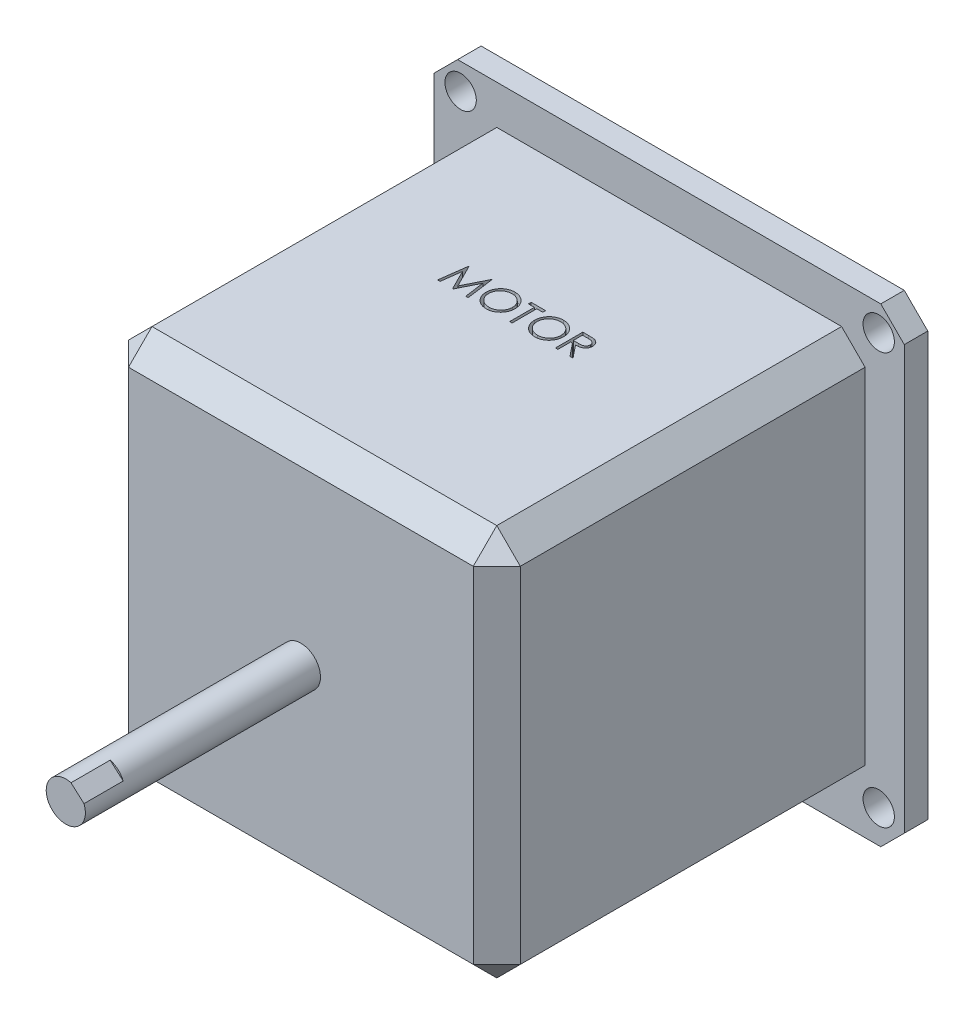
from build123d import *

# Parameters (mm, degrees)
SKETCH1_W             = 50
SKETCH1_H             = 50
BOSS_EXTRUDE1_DEPTH   = 25
CHAMFER1_SIZE         = 3
SKETCH2_R             = 2.5
BOSS_EXTRUDE2_DEPTH   = 50
CUT_EXTRUDE1_DEPTH    = 3
BOSS_EXTRUDE3_DEPTH   = 5
SKETCH5_W             = 60
SKETCH5_H             = 60
BOSS_EXTRUDE4_DEPTH   = 3
F_4_0MM_DOWEL_HOLE1_D = 4
CHAMFER2_SIZE         = 3


with BuildPart() as part:
    # Sketch1 → Boss-Extrude1 (new body, symmetric)
    with BuildSketch(Plane.XY):
        Rectangle(SKETCH1_W, SKETCH1_H)
    extrude(amount=BOSS_EXTRUDE1_DEPTH, both=True)

    # Chamfer1
    chamfer1_edges = [part.edges().sort_by_distance(p)[0] for p in [
        (-25, 0, 25),
        (0, -25, 25),
        (25, 0, 25),
        (0, -25, -25),
        (-25, 0, -25),
        (0, 25, -25),
        (25, 0, -25),
        (0, 25, 25),
        (25, -25, 0),
        (-25, -25, 0),
        (-25, 25, 0),
        (25, 25, 0),
    ]]
    chamfer(chamfer1_edges, length=CHAMFER1_SIZE)

    # Sketch2 → Boss-Extrude2 (add)
    with BuildSketch(Plane.XY):
        Circle(SKETCH2_R)
    extrude(amount=BOSS_EXTRUDE2_DEPTH)

    # Sketch3 → Cut-Extrude1 (cut)
    with BuildSketch(Plane(origin=(0, 25, 0), x_dir=(1, 0, 0), z_dir=(0, 1, 0))):
        Polygon((-8.921076978, 1.368655092), (-8.459037716, 4.868655092), (-8.414165921, 4.868655092), (-6.969153901, 1.99686022), (-5.527647491, 4.868655092), (-5.482074575, 4.868655092), (-5.017230825, 1.368655092), (-5.332735632, 1.368655092), (-5.66787185, 3.887084579), (-6.931293325, 1.368655092), (-7.002106626, 1.368655092), (-8.270435953, 3.892693553), (-8.604871049, 1.368655092), align=None)
        with BuildLine():
            add(Edge.make_bspline(
                [(-2.661461594, 4.958398681), (-2.596653488, 4.956757202), (-2.469365021, 4.953533201), (-2.282290123, 4.928854097), (-2.103695028, 4.886158708), (-1.932124889, 4.829295725), (-1.769631913, 4.75344134), (-1.61499302, 4.661756191), (-1.468576146, 4.553279733), (-1.332354765, 4.428850506), (-1.207697814, 4.293467052), (-1.097871928, 4.148989142), (-1.005829634, 3.996290339), (-0.930243847, 3.835829509), (-0.870945238, 3.667969541), (-0.830026194, 3.491815538), (-0.803888044, 3.308508848), (-0.800832266, 3.183481983), (-0.799282107, 3.120057335)],
                knots=[0, 0, 0, 0, 0.000194393, 0.000381804, 0.00056479, 0.000744601, 0.000923091, 0.001101652, 0.001283106, 0.001468738, 0.001654324, 0.001834514, 0.002012231, 0.002188181, 0.002365797, 0.002545211, 0.002729936, 0.002920126, 0.002920126, 0.002920126, 0.002920126], degree=3))
            add(Edge.make_bspline(
                [(-0.799282107, 3.120057335), (-0.800832039, 3.057099889), (-0.803887136, 2.933003468), (-0.830055913, 2.750860024), (-0.871096913, 2.575769328), (-0.929693179, 2.408023675), (-1.004918658, 2.247446111), (-1.097573829, 2.094459157), (-1.20671504, 1.949012659), (-1.330921891, 1.812699994), (-1.466322933, 1.687702523), (-1.6115532, 1.578783647), (-1.76334652, 1.485059523), (-1.923656228, 1.410275849), (-2.090356265, 1.350503928), (-2.264938588, 1.309751298), (-2.446585142, 1.283464255), (-2.570456145, 1.280445739), (-2.633416722, 1.278911502)],
                knots=[0, 0, 0, 0, 0.000188789, 0.000372126, 0.000550857, 0.00072758, 0.000904164, 0.001081881, 0.001263191, 0.001448823, 0.00163441, 0.001815159, 0.001992641, 0.002168591, 0.002344885, 0.002522934, 0.002705576, 0.002894365, 0.002894365, 0.002894365, 0.002894365], degree=3))
            add(Edge.make_bspline(
                [(-2.633416722, 1.278911502), (-2.696841041, 1.280460889), (-2.821867257, 1.283515143), (-3.005404292, 1.309696547), (-3.181682036, 1.350637851), (-3.350196387, 1.409147287), (-3.511041317, 1.484764518), (-3.6645314, 1.576968897), (-3.810050547, 1.686376038), (-3.946392293, 1.810542613), (-4.071141492, 1.945714165), (-4.179900867, 2.09054842), (-4.272125981, 2.242203877), (-4.347489313, 2.401101401), (-4.407153772, 2.566472844), (-4.447858591, 2.739421321), (-4.474194543, 2.918960827), (-4.477229389, 3.041203725), (-4.478769286, 3.103230412)],
                knots=[0, 0, 0, 0, 0.00019019, 0.000374915, 0.000555011, 0.000732396, 0.00090898, 0.001087298, 0.001268608, 0.00145424, 0.001639827, 0.001819595, 0.001996712, 0.002171394, 0.002346367, 0.002523053, 0.002703612, 0.002889599, 0.002889599, 0.002889599, 0.002889599], degree=3))
            add(Edge.make_bspline(
                [(-4.478769286, 3.103230412), (-4.478234651, 3.144863081), (-4.477172124, 3.227603205), (-4.464380432, 3.350469805), (-4.445818731, 3.471360463), (-4.419216818, 3.589931411), (-4.384425151, 3.705892395), (-4.343373124, 3.820043158), (-4.293233278, 3.931226882), (-4.23655263, 4.039970274), (-4.173290822, 4.144578179), (-4.103415073, 4.243457763), (-4.029379704, 4.337438759), (-3.948216311, 4.424085763), (-3.862599866, 4.50591942), (-3.771141487, 4.581682137), (-3.674399243, 4.652057088), (-3.571956863, 4.715477429), (-3.466338588, 4.772836563), (-3.357461811, 4.822058414), (-3.246805239, 4.864304476), (-3.133850591, 4.898545301), (-3.018897819, 4.925577337), (-2.901696034, 4.943984691), (-2.782338608, 4.956809009), (-2.701927289, 4.957866511), (-2.661461594, 4.958398681)],
                knots=[0, 0, 0, 0, 0.000124849, 0.000248123, 0.000370193, 0.00049164, 0.000612319, 0.000733199, 0.000855287, 0.000977905, 0.001100913, 0.001221706, 0.001340948, 0.001459521, 0.001577551, 0.001696047, 0.001815534, 0.001936153, 0.002057243, 0.002175846, 0.002294342, 0.002412335, 0.002529682, 0.00264829, 0.002768075, 0.00288942, 0.00288942, 0.00288942, 0.00288942], degree=3))
        make_face()
        with BuildLine():
            add(Edge.make_bspline(
                [(-2.646036914, 4.599424322), (-2.679251548, 4.599019432), (-2.745363281, 4.598213522), (-2.843647817, 4.587597807), (-2.940639751, 4.572467918), (-3.036359113, 4.550886397), (-3.130405402, 4.521482344), (-3.223655244, 4.487641436), (-3.315258297, 4.446420345), (-3.404912155, 4.399847641), (-3.49182723, 4.34829872), (-3.573839932, 4.291326953), (-3.651162576, 4.230268399), (-3.723605843, 4.164980562), (-3.790957015, 4.09513096), (-3.854541716, 4.021778524), (-3.911811298, 3.942826633), (-3.964296875, 3.860416226), (-4.011264715, 3.774654645), (-4.05303007, 3.686444782), (-4.087194078, 3.595067096), (-4.115056455, 3.501512938), (-4.138156266, 3.405930478), (-4.15279019, 3.30759463), (-4.163522549, 3.206999517), (-4.164282395, 3.139017663), (-4.164666722, 3.104632656)],
                knots=[0, 0, 0, 0, 9.9599e-05, 0.000198245, 0.000296222, 0.00039402, 0.00049227, 0.000591646, 0.000691452, 0.000793368, 0.000894612, 0.000994383, 0.001092713, 0.00119001, 0.001286696, 0.001383657, 0.001480979, 0.001579008, 0.001676595, 0.001774142, 0.001871547, 0.001968922, 0.002066879, 0.00216624, 0.00226698, 0.002370083, 0.002370083, 0.002370083, 0.002370083], degree=3))
            add(Edge.make_bspline(
                [(-4.164666722, 3.104632656), (-4.16339186, 3.054070435), (-4.160883812, 2.954598905), (-4.138926242, 2.808830761), (-4.105104268, 2.668742474), (-4.055246901, 2.535100565), (-3.992896287, 2.406756282), (-3.915869396, 2.284848178), (-3.824610311, 2.169343303), (-3.720946784, 2.061048034), (-3.607624077, 1.96220223), (-3.487291348, 1.875438821), (-3.36123774, 1.802028572), (-3.229134537, 1.742223499), (-3.091686998, 1.694833761), (-2.948009447, 1.66235513), (-2.799058988, 1.640979675), (-2.697528333, 1.638926919), (-2.646036914, 1.637885861)],
                knots=[0, 0, 0, 0, 0.000151605, 0.000298253, 0.000441263, 0.000583229, 0.000725274, 0.000868635, 0.001014928, 0.001166177, 0.001317744, 0.00146543, 0.001610576, 0.001754594, 0.001899821, 0.002045914, 0.002195936, 0.002350312, 0.002350312, 0.002350312, 0.002350312], degree=3))
            add(Edge.make_bspline(
                [(-2.646036914, 1.637885861), (-2.611427413, 1.638361365), (-2.542786376, 1.639304433), (-2.440690854, 1.64880311), (-2.340434642, 1.664034979), (-2.242158362, 1.685965635), (-2.145973551, 1.713412841), (-2.051478748, 1.746020569), (-1.959680458, 1.786701773), (-1.86942062, 1.831649725), (-1.783024378, 1.882889882), (-1.700548846, 1.937928032), (-1.624072866, 1.998896653), (-1.551683794, 2.063214465), (-1.484056105, 2.132178313), (-1.421647121, 2.205698535), (-1.364666989, 2.284239192), (-1.312201343, 2.366524598), (-1.26539808, 2.45252085), (-1.224618981, 2.541050528), (-1.190022865, 2.631895638), (-1.16209436, 2.725187209), (-1.140208898, 2.820748058), (-1.125128978, 2.918706136), (-1.11458054, 3.018865479), (-1.113785463, 3.086609335), (-1.113384671, 3.120758457)],
                knots=[0, 0, 0, 0, 0.000103804, 0.000205874, 0.000307314, 0.000407849, 0.000507719, 0.000607281, 0.000707445, 0.000808723, 0.000909609, 0.001008589, 0.001105934, 0.001202762, 0.001298946, 0.001395452, 0.001491794, 0.001589823, 0.001688026, 0.001785277, 0.001882027, 0.001979402, 0.0020772, 0.002175869, 0.002276609, 0.002379011, 0.002379011, 0.002379011, 0.002379011], degree=3))
            add(Edge.make_bspline(
                [(-1.113384671, 3.120758457), (-1.113785784, 3.154673961), (-1.114581465, 3.221951611), (-1.12512394, 3.32141243), (-1.14022483, 3.418665641), (-1.161987538, 3.513329444), (-1.190037692, 3.605427969), (-1.224625022, 3.694874717), (-1.265410322, 3.782002912), (-1.312218546, 3.866597209), (-1.36483437, 3.947771947), (-1.422328613, 4.02537436), (-1.485693961, 4.097947101), (-1.553119986, 4.167281795), (-1.626290871, 4.231899685), (-1.704875165, 4.291822205), (-1.787918843, 4.34849548), (-1.875846079, 4.399621041), (-1.966590032, 4.446835274), (-2.05970399, 4.487286277), (-2.15413309, 4.521658397), (-2.249637202, 4.550975362), (-2.347020181, 4.572383392), (-2.445624009, 4.587611442), (-2.545312268, 4.598209828), (-2.612355488, 4.599018206), (-2.646036914, 4.599424322)],
                knots=[0, 0, 0, 0, 0.000101701, 0.000201743, 0.00029972, 0.000396835, 0.000492868, 0.000588308, 0.000684288, 0.000781261, 0.000878109, 0.000974304, 0.001070733, 0.001166917, 0.001264269, 0.001363274, 0.001463228, 0.001565678, 0.001668217, 0.001769947, 0.001869982, 0.001969573, 0.002069423, 0.002168785, 0.002268827, 0.002369827, 0.002369827, 0.002369827, 0.002369827], degree=3))
        make_face(mode=Mode.SUBTRACT)
        Polygon((-0.485179543, 4.509680733), (-0.485179543, 4.868655092), (1.354564047, 4.868655092), (1.354564047, 4.509680733), (0.591743534, 4.509680733), (0.591743534, 1.368655092), (0.27764097, 1.368655092), (0.27764097, 4.509680733), align=None)
        with BuildLine():
            add(Edge.make_bspline(
                [(3.530846099, 4.958398681), (3.595654204, 4.956757202), (3.722942671, 4.953533201), (3.910017569, 4.928854097), (4.088612664, 4.886158708), (4.260182803, 4.829295725), (4.42267578, 4.75344134), (4.577314672, 4.661756191), (4.723731546, 4.553279733), (4.859952928, 4.428850506), (4.984609878, 4.293467052), (5.094435764, 4.148989142), (5.186478058, 3.996290339), (5.262063845, 3.835829509), (5.321362455, 3.667969541), (5.362281498, 3.491815538), (5.388419649, 3.308508848), (5.391475426, 3.183481983), (5.393025586, 3.120057335)],
                knots=[0, 0, 0, 0, 0.000194393, 0.000381804, 0.00056479, 0.000744601, 0.000923091, 0.001101652, 0.001283106, 0.001468738, 0.001654324, 0.001834514, 0.002012231, 0.002188181, 0.002365797, 0.002545211, 0.002729936, 0.002920126, 0.002920126, 0.002920126, 0.002920126], degree=3))
            add(Edge.make_bspline(
                [(5.393025586, 3.120057335), (5.391475653, 3.057099889), (5.388420557, 2.933003468), (5.362251779, 2.750860024), (5.321210779, 2.575769328), (5.262614513, 2.408023675), (5.187389034, 2.247446111), (5.094733863, 2.094459157), (4.985592653, 1.949012659), (4.861385802, 1.812699994), (4.72598476, 1.687702523), (4.580754493, 1.578783647), (4.428961173, 1.485059523), (4.268651465, 1.410275849), (4.101951428, 1.350503928), (3.927369105, 1.309751298), (3.745722551, 1.283464255), (3.621851547, 1.280445739), (3.55889097, 1.278911502)],
                knots=[0, 0, 0, 0, 0.000188789, 0.000372126, 0.000550857, 0.00072758, 0.000904164, 0.001081881, 0.001263191, 0.001448823, 0.00163441, 0.001815159, 0.001992641, 0.002168591, 0.002344885, 0.002522934, 0.002705576, 0.002894365, 0.002894365, 0.002894365, 0.002894365], degree=3))
            add(Edge.make_bspline(
                [(3.55889097, 1.278911502), (3.495466651, 1.280460889), (3.370440435, 1.283515143), (3.1869034, 1.309696547), (3.010625656, 1.350637851), (2.842111305, 1.409147287), (2.681266375, 1.484764518), (2.527776293, 1.576968897), (2.382257145, 1.686376038), (2.245915399, 1.810542613), (2.121166201, 1.945714165), (2.012406825, 2.09054842), (1.920181712, 2.242203877), (1.844818379, 2.401101401), (1.78515392, 2.566472844), (1.744449102, 2.739421321), (1.71811315, 2.918960827), (1.715078303, 3.041203725), (1.713538406, 3.103230412)],
                knots=[0, 0, 0, 0, 0.00019019, 0.000374915, 0.000555011, 0.000732396, 0.00090898, 0.001087298, 0.001268608, 0.00145424, 0.001639827, 0.001819595, 0.001996712, 0.002171394, 0.002346367, 0.002523053, 0.002703612, 0.002889599, 0.002889599, 0.002889599, 0.002889599], degree=3))
            add(Edge.make_bspline(
                [(1.713538406, 3.103230412), (1.714073042, 3.144863081), (1.715135568, 3.227603205), (1.727927261, 3.350469805), (1.746488962, 3.471360463), (1.773090874, 3.589931411), (1.807882541, 3.705892395), (1.848934569, 3.820043158), (1.899074414, 3.931226882), (1.955755062, 4.039970274), (2.01901687, 4.144578179), (2.08889262, 4.243457763), (2.162927988, 4.337438759), (2.244091382, 4.424085763), (2.329707827, 4.50591942), (2.421166205, 4.581682137), (2.517908449, 4.652057088), (2.620350829, 4.715477429), (2.725969104, 4.772836563), (2.834845882, 4.822058414), (2.945502453, 4.864304476), (3.058457101, 4.898545301), (3.173409873, 4.925577337), (3.290611658, 4.943984691), (3.409969084, 4.956809009), (3.490380403, 4.957866511), (3.530846099, 4.958398681)],
                knots=[0, 0, 0, 0, 0.000124849, 0.000248123, 0.000370193, 0.00049164, 0.000612319, 0.000733199, 0.000855287, 0.000977905, 0.001100913, 0.001221706, 0.001340948, 0.001459521, 0.001577551, 0.001696047, 0.001815534, 0.001936153, 0.002057243, 0.002175846, 0.002294342, 0.002412335, 0.002529682, 0.00264829, 0.002768075, 0.00288942, 0.00288942, 0.00288942, 0.00288942], degree=3))
        make_face()
        with BuildLine():
            add(Edge.make_bspline(
                [(3.546270778, 4.599424322), (3.513056144, 4.599019432), (3.446944412, 4.598213522), (3.348659875, 4.587597807), (3.251667941, 4.572467918), (3.155948579, 4.550886397), (3.06190229, 4.521482344), (2.968652449, 4.487641436), (2.877049395, 4.446420345), (2.787395537, 4.399847641), (2.700480462, 4.34829872), (2.61846776, 4.291326953), (2.541145116, 4.230268399), (2.46870185, 4.164980562), (2.401350678, 4.09513096), (2.337765976, 4.021778524), (2.280496394, 3.942826633), (2.228010818, 3.860416226), (2.181042977, 3.774654645), (2.139277623, 3.686444782), (2.105113614, 3.595067096), (2.077251238, 3.501512938), (2.054151427, 3.405930478), (2.039517503, 3.30759463), (2.028785143, 3.206999517), (2.028025298, 3.139017663), (2.02764097, 3.104632656)],
                knots=[0, 0, 0, 0, 9.9599e-05, 0.000198245, 0.000296222, 0.00039402, 0.00049227, 0.000591646, 0.000691452, 0.000793368, 0.000894612, 0.000994383, 0.001092713, 0.00119001, 0.001286696, 0.001383657, 0.001480979, 0.001579008, 0.001676595, 0.001774142, 0.001871547, 0.001968922, 0.002066879, 0.00216624, 0.00226698, 0.002370083, 0.002370083, 0.002370083, 0.002370083], degree=3))
            add(Edge.make_bspline(
                [(2.02764097, 3.104632656), (2.028915832, 3.054070435), (2.03142388, 2.954598905), (2.05338145, 2.808830761), (2.087203425, 2.668742474), (2.137060791, 2.535100565), (2.199411406, 2.406756282), (2.276438296, 2.284848178), (2.367697382, 2.169343303), (2.471360908, 2.061048034), (2.584683615, 1.96220223), (2.705016345, 1.875438821), (2.831069952, 1.802028572), (2.963173155, 1.742223499), (3.100620694, 1.694833761), (3.244298245, 1.66235513), (3.393248705, 1.640979675), (3.49477936, 1.638926919), (3.546270778, 1.637885861)],
                knots=[0, 0, 0, 0, 0.000151605, 0.000298253, 0.000441263, 0.000583229, 0.000725274, 0.000868635, 0.001014928, 0.001166177, 0.001317744, 0.00146543, 0.001610576, 0.001754594, 0.001899821, 0.002045914, 0.002195936, 0.002350312, 0.002350312, 0.002350312, 0.002350312], degree=3))
            add(Edge.make_bspline(
                [(3.546270778, 1.637885861), (3.58088028, 1.638361365), (3.649521316, 1.639304433), (3.751616838, 1.64880311), (3.85187305, 1.664034979), (3.95014933, 1.685965635), (4.046334141, 1.713412841), (4.140828944, 1.746020569), (4.232627235, 1.786701773), (4.322887073, 1.831649725), (4.409283314, 1.882889882), (4.491758847, 1.937928032), (4.568234826, 1.998896653), (4.640623898, 2.063214465), (4.708251587, 2.132178313), (4.770660571, 2.205698535), (4.827640703, 2.284239192), (4.88010635, 2.366524598), (4.926909613, 2.45252085), (4.967688712, 2.541050528), (5.002284827, 2.631895638), (5.030213332, 2.725187209), (5.052098794, 2.820748058), (5.067178714, 2.918706136), (5.077727152, 3.018865479), (5.07852223, 3.086609335), (5.078923022, 3.120758457)],
                knots=[0, 0, 0, 0, 0.000103804, 0.000205874, 0.000307314, 0.000407849, 0.000507719, 0.000607281, 0.000707445, 0.000808723, 0.000909609, 0.001008589, 0.001105934, 0.001202762, 0.001298946, 0.001395452, 0.001491794, 0.001589823, 0.001688026, 0.001785277, 0.001882027, 0.001979402, 0.0020772, 0.002175869, 0.002276609, 0.002379011, 0.002379011, 0.002379011, 0.002379011], degree=3))
            add(Edge.make_bspline(
                [(5.078923022, 3.120758457), (5.078521909, 3.154673961), (5.077726227, 3.221951611), (5.067183752, 3.32141243), (5.052082862, 3.418665641), (5.030320154, 3.513329444), (5.00227, 3.605427969), (4.96768267, 3.694874717), (4.92689737, 3.782002912), (4.880089146, 3.866597209), (4.827473323, 3.947771947), (4.769979079, 4.02537436), (4.706613731, 4.097947101), (4.639187706, 4.167281795), (4.566016821, 4.231899685), (4.487432527, 4.291822205), (4.404388849, 4.34849548), (4.316461614, 4.399621041), (4.22571766, 4.446835274), (4.132603702, 4.487286277), (4.038174602, 4.521658397), (3.94267049, 4.550975362), (3.845287512, 4.572383392), (3.746683683, 4.587611442), (3.646995424, 4.598209828), (3.579952205, 4.599018206), (3.546270778, 4.599424322)],
                knots=[0, 0, 0, 0, 0.000101701, 0.000201743, 0.00029972, 0.000396835, 0.000492868, 0.000588308, 0.000684288, 0.000781261, 0.000878109, 0.000974304, 0.001070733, 0.001166917, 0.001264269, 0.001363274, 0.001463228, 0.001565678, 0.001668217, 0.001769947, 0.001869982, 0.001969573, 0.002069423, 0.002168785, 0.002268827, 0.002369827, 0.002369827, 0.002369827, 0.002369827], degree=3))
        make_face(mode=Mode.SUBTRACT)
        with BuildLine():
            Line((6.110974304, 4.868655092), (6.811394977, 4.868655092))
            add(Edge.make_bspline(
                [(6.811394977, 4.868655092), (6.858136105, 4.868499506), (6.94788425, 4.868200763), (7.07645752, 4.866535), (7.193284617, 4.861760645), (7.298304456, 4.857652061), (7.391515111, 4.85016012), (7.473202402, 4.842999473), (7.5429901, 4.833625812), (7.585235951, 4.824920389), (7.604363727, 4.82097881)],
                knots=[0, 0, 0, 0, 0.000140226, 0.00026925, 0.000385712, 0.000490995, 0.000584507, 0.000666202, 0.000736998, 0.000795574, 0.000795574, 0.000795574, 0.000795574], degree=3))
            add(Edge.make_bspline(
                [(7.604363727, 4.82097881), (7.629970351, 4.814652044), (7.68063734, 4.802133481), (7.753587406, 4.77567388), (7.82310173, 4.745054255), (7.888891555, 4.709090535), (7.950627346, 4.667515755), (8.008945657, 4.621047633), (8.06411112, 4.569940427), (8.11389275, 4.512905585), (8.160831802, 4.453069076), (8.200420428, 4.388365319), (8.234546908, 4.320703791), (8.261717425, 4.249396374), (8.283595399, 4.175134602), (8.299021638, 4.097245805), (8.308272826, 4.01608483), (8.309214681, 3.960726921), (8.309692252, 3.932657495)],
                knots=[0, 0, 0, 0, 7.9081e-05, 0.000156475, 0.000232432, 0.000306798, 0.00038108, 0.000455429, 0.000530331, 0.000606314, 0.000682321, 0.000758201, 0.000833453, 0.000909362, 0.000986794, 0.001065445, 0.001147284, 0.001231465, 0.001231465, 0.001231465, 0.001231465], degree=3))
            add(Edge.make_bspline(
                [(8.309692252, 3.932657495), (8.308223254, 3.886022391), (8.305356858, 3.795025223), (8.278631755, 3.662964342), (8.234855235, 3.539775027), (8.174531946, 3.425612389), (8.09771247, 3.322701744), (8.005387679, 3.232311288), (7.897506068, 3.156671376), (7.797076752, 3.104218571), (7.708362552, 3.070625662), (7.635329239, 3.046989304), (7.555662262, 3.028727338), (7.470124927, 3.012367206), (7.378361272, 3.000015512), (7.280591232, 2.990968918), (7.176745081, 2.985314869), (7.105406011, 2.984472864), (7.068706675, 2.984039707)],
                knots=[0, 0, 0, 0, 0.000139777, 0.000272741, 0.000402249, 0.000530843, 0.000658588, 0.000786009, 0.000916741, 0.001052522, 0.001124656, 0.001201155, 0.001282612, 0.001369656, 0.001462366, 0.001560247, 0.001664165, 0.001774261, 0.001774261, 0.001774261, 0.001774261], degree=3))
            Line((7.068706675, 2.984039707), (8.354564047, 1.368655092))
            Line((8.354564047, 1.368655092), (7.966142573, 1.368655092))
            Line((7.966142573, 1.368655092), (6.680285201, 2.984039707))
            Line((6.680285201, 2.984039707), (6.425076868, 2.984039707))
            Line((6.425076868, 2.984039707), (6.425076868, 1.368655092))
            Line((6.425076868, 1.368655092), (6.110974304, 1.368655092))
            Line((6.110974304, 1.368655092), (6.110974304, 4.868655092))
        make_face()
        with BuildLine():
            Line((6.425076868, 4.509680733), (6.425076868, 3.343014066))
            Line((6.425076868, 3.343014066), (7.065902188, 3.338106213))
            add(Edge.make_bspline(
                [(7.065902188, 3.338106213), (7.095822227, 3.338092977), (7.153815784, 3.33806732), (7.237716449, 3.342061097), (7.315836561, 3.346604415), (7.387877313, 3.35355376), (7.453870888, 3.362509832), (7.513784301, 3.373712816), (7.567715353, 3.386764879), (7.630613892, 3.406966505), (7.700850423, 3.438972523), (7.777181883, 3.485538022), (7.842184221, 3.544107141), (7.897102083, 3.611080597), (7.941231515, 3.684716846), (7.972343569, 3.764133215), (7.992086011, 3.847324813), (7.994414557, 3.904502921), (7.995589688, 3.933358617)],
                knots=[0, 0, 0, 0, 8.9746e-05, 0.000173954, 0.000251933, 0.000324488, 0.000391021, 0.000451663, 0.000507268, 0.000557378, 0.000649639, 0.000738152, 0.000824558, 0.000910739, 0.000997194, 0.001080909, 0.00116578, 0.001252248, 0.001252248, 0.001252248, 0.001252248], degree=3))
            add(Edge.make_bspline(
                [(7.995589688, 3.933358617), (7.994387567, 3.961505191), (7.992005402, 4.01728143), (7.972556633, 4.09893734), (7.939667252, 4.17600429), (7.895345014, 4.248168775), (7.841345859, 4.313674511), (7.778028046, 4.369721664), (7.707122851, 4.415971129), (7.640851653, 4.445525509), (7.58161744, 4.463645362), (7.53018778, 4.476396526), (7.472076303, 4.486640995), (7.407000844, 4.494849056), (7.335239213, 4.501904), (7.256428562, 4.506655779), (7.171091782, 4.509469643), (7.111944851, 4.509608732), (7.081326868, 4.509680733)],
                knots=[0, 0, 0, 0, 8.4371e-05, 0.000167192, 0.000250141, 0.000334794, 0.000420435, 0.000503871, 0.000587493, 0.000673488, 0.0007205, 0.000773215, 0.000832351, 0.0008974, 0.000969955, 0.001048634, 0.001134217, 0.001226067, 0.001226067, 0.001226067, 0.001226067], degree=3))
            Line((7.081326868, 4.509680733), (6.425076868, 4.509680733))
        make_face(mode=Mode.SUBTRACT)
    extrude(amount=-CUT_EXTRUDE1_DEPTH, mode=Mode.SUBTRACT)

    # Sketch4 → Boss-Extrude3 (add)
    with BuildSketch(Plane.XY.offset(50)):
        with BuildLine():
            Line((0.664166373, 2.410162449), (2.320837892, 0.929360791))
            ThreePointArc((2.320837892, 0.929360791), (-1.666060023, -1.863932402), (0.664166373, 2.410162449))
        make_face()
    extrude(amount=BOSS_EXTRUDE3_DEPTH)

    # Sketch5 → Boss-Extrude4 (add)
    with BuildSketch(Plane(origin=(0, 0, -25), x_dir=(-1, 0, 0), z_dir=(0, 0, -1))):
        Rectangle(SKETCH5_W, SKETCH5_H)
    extrude(amount=-BOSS_EXTRUDE4_DEPTH)

    # Ø4.0mm Dowel Hole1 (through all)
    with Locations(Plane(origin=(0, 0, -25), x_dir=(-1, 0, 0), z_dir=(0, 0, -1))):
        with Locations((26.616304112, 26.678491738), (-26.740679364, 26.678491738), (-26.740679364, -25.807864968), (26.616304112, -25.807864968)):
            Hole(F_4_0MM_DOWEL_HOLE1_D / 2)

    # Chamfer2
    chamfer2_edges = [part.edges().sort_by_distance(p)[0] for p in [
        (30, -30, -23.5),
        (30, 30, -23.5),
        (-30, 30, -23.5),
        (-30, -30, -23.5),
    ]]
    chamfer(chamfer2_edges, length=CHAMFER2_SIZE)


solid = part.part
